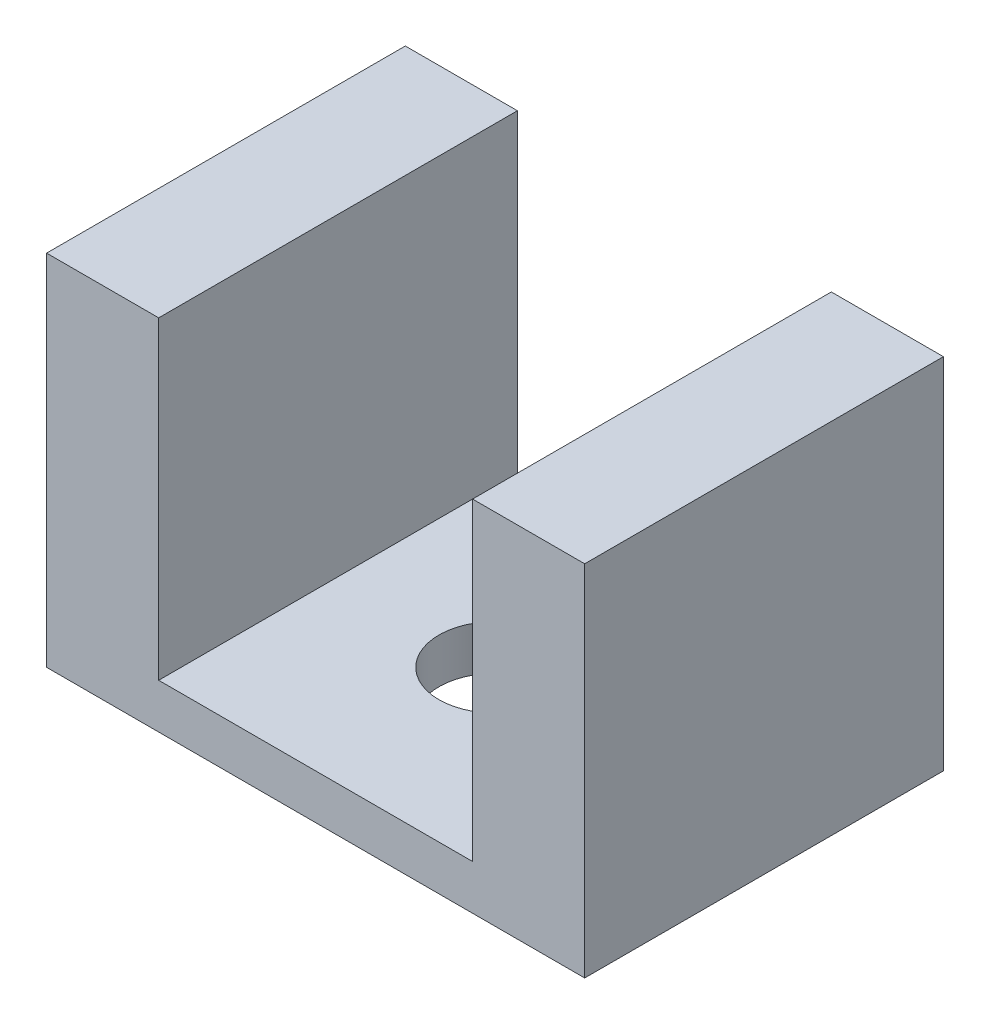
from build123d import *

# Parameters (mm, degrees)
BOSS_EXTRUDE1_DEPTH = 50.8
SKETCH2_R           = 7.9375
CUT_EXTRUDE1_DEPTH  = 7.35


with BuildPart() as part:
    # Sketch1 → Boss-Extrude1 (new body)
    with BuildSketch(Plane.XY):
        Polygon((22.225, 0), (-22.225, 0), (-22.225, 44.45), (-38.1, 44.45), (-38.1, -6.35), (38.1, -6.35), (38.1, 44.45), (22.225, 44.45), align=None)
    extrude(amount=BOSS_EXTRUDE1_DEPTH)

    # Sketch2 → Cut-Extrude1 (cut, through all)
    with BuildSketch(Plane(origin=(0, 0, 0), x_dir=(1, 0, 0), z_dir=(0, 1, 0))):
        with Locations((0, -25.4)):
            Circle(SKETCH2_R)
    extrude(amount=-CUT_EXTRUDE1_DEPTH, mode=Mode.SUBTRACT)


solid = part.part
